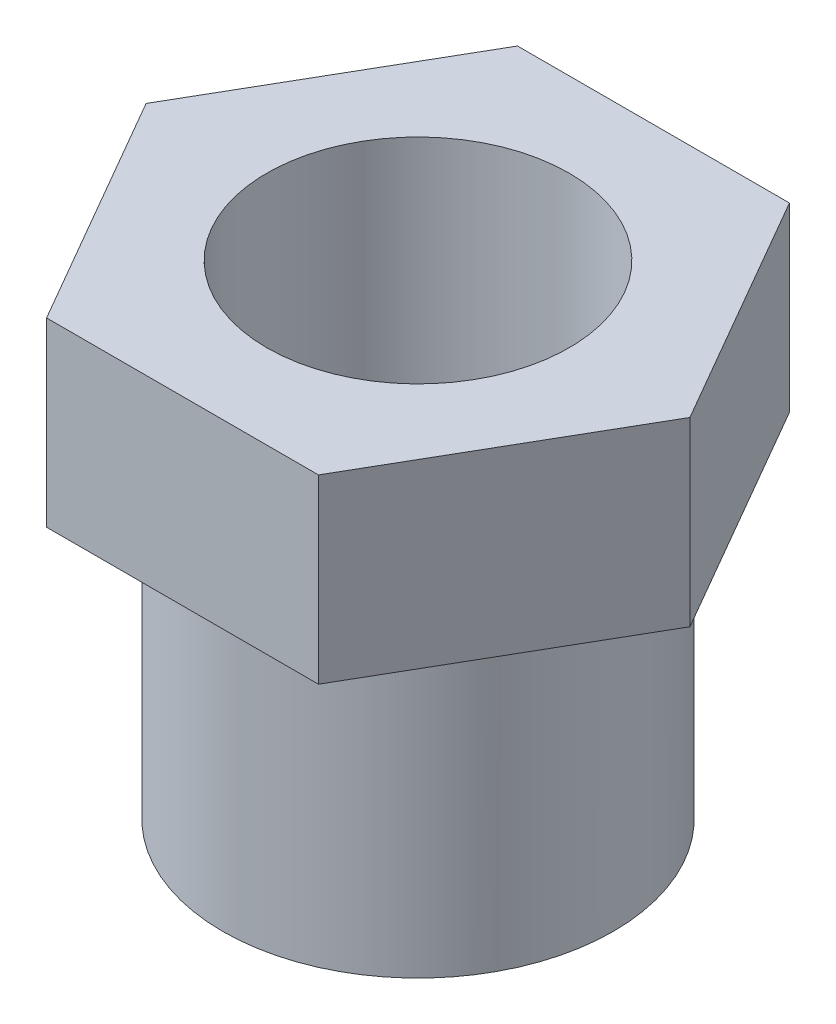
from build123d import *

# Parameters (mm, degrees)
SALIENTE_EXTRUIR1_DEPTH = 15
CROQUIS2_R              = 16.164040976
SALIENTE_EXTRUIR2_DEPTH = 25
CROQUIS4_R              = 12.514075771
CORTAR_EXTRUIR1_DEPTH   = 61


with BuildPart() as part:
    # Croquis1 → Saliente-Extruir1 (new body)
    with BuildSketch(Plane(origin=(0, 0, 0), x_dir=(1, 0, 0), z_dir=(0, 1, 0))):
        Polygon((22.5, 0), (11.25, 19.485571585), (-11.25, 19.485571585), (-22.5, 0), (-11.25, -19.485571585), (11.25, -19.485571585), align=None)
    extrude(amount=SALIENTE_EXTRUIR1_DEPTH)

    # Croquis2 → Saliente-Extruir2 (add)
    with BuildSketch(Plane.XZ):
        Circle(CROQUIS2_R)
    extrude(amount=SALIENTE_EXTRUIR2_DEPTH)

    # Croquis4 → Cortar-Extruir1 (cut, through all)
    with BuildSketch(Plane.XZ.offset(45)):
        Circle(CROQUIS4_R)
    extrude(amount=-CORTAR_EXTRUIR1_DEPTH, mode=Mode.SUBTRACT)


solid = part.part
